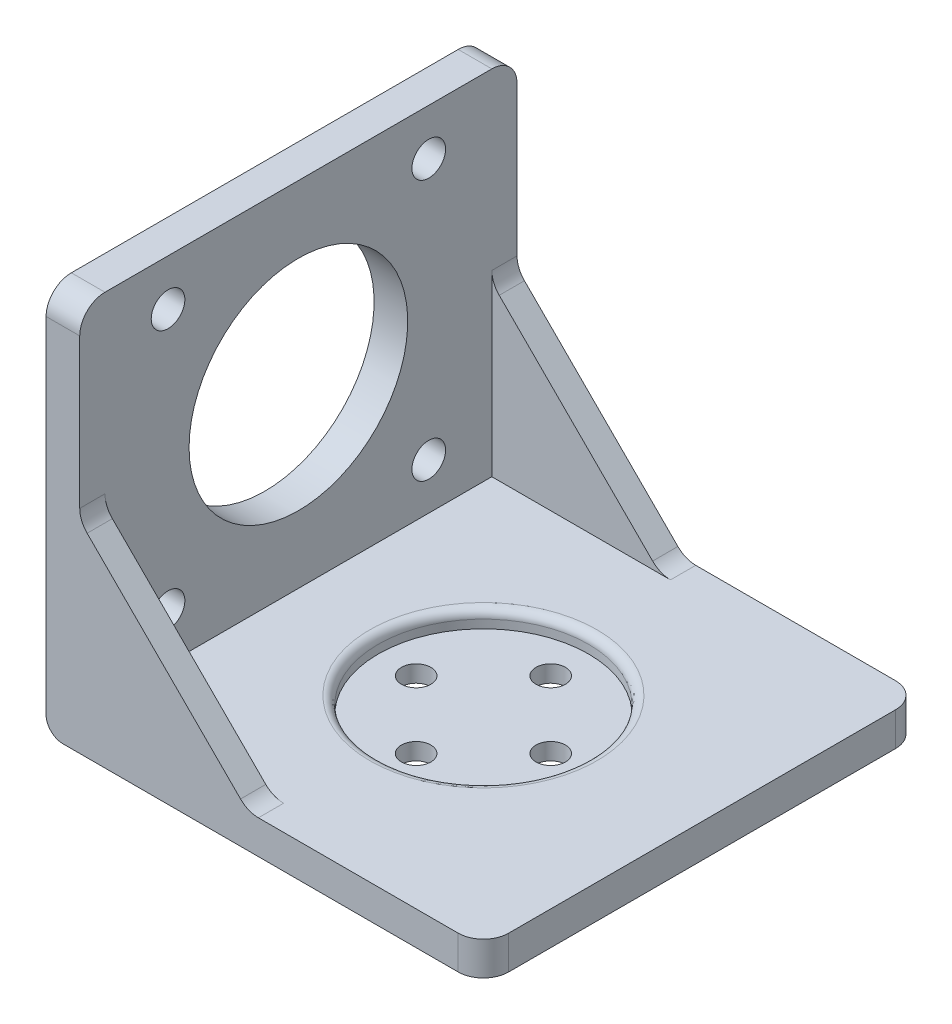
from build123d import *

# Parameters (mm, degrees)
SKETCH_1_W          = 52
SKETCH_1_H          = 46
SKETCH_1_R          = 1.75
EXTRUDE_2_DEPTH     = 4
SKETCH_2_W          = 46
SKETCH_2_H          = 42
SKETCH_2_R          = 2
SKETCH_2_R_2        = 13
EXTRUDE_3_DEPTH     = 4
SKETCH_4_R          = 12.5
CUT_EXTRUDE_1_DEPTH = 2
EXTRUDE_4_DEPTH     = 3
EXTRUDE_5_DEPTH     = 3
FILLET_1_R          = 3
FILLET_2_R          = 3
FILLET_3_R          = 3
FILLET_4_R          = 3
FILLET_5_R          = 3
FILLET_6_R          = 3
FILLET_7_R          = 3
FILLET_8_R          = 3
FILLET_9_R          = 1
FILLET_10_R         = 2


with BuildPart() as part:
    # 草图1 → 凸台-拉伸2 (new body)
    with BuildSketch(Plane(origin=(0, 0, 0), x_dir=(1, 0, 0), z_dir=(0, 1, 0))):
        Rectangle(SKETCH_1_W, SKETCH_1_H)
        with Locations((8, 0)):
            Circle(SKETCH_1_R, mode=Mode.SUBTRACT)
        with Locations((0, 8)):
            Circle(SKETCH_1_R, mode=Mode.SUBTRACT)
        with Locations((-8, 0)):
            Circle(SKETCH_1_R, mode=Mode.SUBTRACT)
        with Locations((0, -8)):
            Circle(SKETCH_1_R, mode=Mode.SUBTRACT)
    extrude(amount=EXTRUDE_2_DEPTH)

    # 草图2 → 凸台-拉伸3 (add)
    with BuildSketch(Plane.ZY.offset(26)):
        with Locations((0, 25)):
            Rectangle(SKETCH_2_W, SKETCH_2_H)
        with Locations((15.5, 40.5)):
            Circle(SKETCH_2_R, mode=Mode.SUBTRACT)
        with Locations((15.5, 9.5)):
            Circle(SKETCH_2_R, mode=Mode.SUBTRACT)
        with Locations((-15.5, 9.5)):
            Circle(SKETCH_2_R, mode=Mode.SUBTRACT)
        with Locations((-15.5, 40.5)):
            Circle(SKETCH_2_R, mode=Mode.SUBTRACT)
        with Locations((0, 25)):
            Circle(SKETCH_2_R_2, mode=Mode.SUBTRACT)
    extrude(amount=-EXTRUDE_3_DEPTH)

    # 草图4 → 切除-拉伸1 (cut)
    with BuildSketch(Plane(origin=(0, 4, 0), x_dir=(1, 0, 0), z_dir=(0, 1, 0))):
        Circle(SKETCH_4_R)
    extrude(amount=-CUT_EXTRUDE_1_DEPTH, mode=Mode.SUBTRACT)

    # 草图6 → 凸台-拉伸4 (add)
    with BuildSketch(Plane.XY.offset(23)):
        Polygon((-26, 46), (-22, 46), (-22, 24), (-2, 4), (26, 4), (26, 0), (-26, 0), align=None)
    extrude(amount=EXTRUDE_4_DEPTH)

    # 草图7 → 凸台-拉伸5 (add)
    with BuildSketch(Plane(origin=(0, 0, -23), x_dir=(-1, 0, 0), z_dir=(0, 0, -1))):
        Polygon((26, 46), (26, 0), (-26, 0), (-26, 4), (2, 4), (22, 24), (22, 46), align=None)
    extrude(amount=EXTRUDE_5_DEPTH)

    # 圆角1
    fillet_1_edges = [part.edges().sort_by_distance(p)[0] for p in [
        (-24, 46, 26),
    ]]
    fillet(fillet_1_edges, radius=FILLET_1_R)

    # 圆角2
    fillet_2_edges = [part.edges().sort_by_distance(p)[0] for p in [
        (-24, 46, -26),
    ]]
    fillet(fillet_2_edges, radius=FILLET_2_R)

    # 圆角3
    fillet_3_edges = [part.edges().sort_by_distance(p)[0] for p in [
        (26, 2, 26),
    ]]
    fillet(fillet_3_edges, radius=FILLET_3_R)

    # 圆角4
    fillet_4_edges = [part.edges().sort_by_distance(p)[0] for p in [
        (26, 2, -26),
    ]]
    fillet(fillet_4_edges, radius=FILLET_4_R)

    # 圆角5
    fillet_5_edges = [part.edges().sort_by_distance(p)[0] for p in [
        (-22, 24, 24.5),
    ]]
    fillet(fillet_5_edges, radius=FILLET_5_R)

    # 圆角6
    fillet_6_edges = [part.edges().sort_by_distance(p)[0] for p in [
        (-2, 4, 24.5),
    ]]
    fillet(fillet_6_edges, radius=FILLET_6_R)

    # 圆角7
    fillet_7_edges = [part.edges().sort_by_distance(p)[0] for p in [
        (-22, 24, -24.5),
    ]]
    fillet(fillet_7_edges, radius=FILLET_7_R)

    # 圆角8
    fillet_8_edges = [part.edges().sort_by_distance(p)[0] for p in [
        (-2, 4, -24.5),
    ]]
    fillet(fillet_8_edges, radius=FILLET_8_R)

    # 圆角9
    fillet_9_edges = [part.edges().sort_by_distance(p)[0] for p in [
        (-12.5, 4, 0),
    ]]
    fillet(fillet_9_edges, radius=FILLET_9_R)

    # 圆角10
    fillet_10_edges = [part.edges().sort_by_distance(p)[0] for p in [
        (-26, 0, 0),
    ]]
    fillet(fillet_10_edges, radius=FILLET_10_R)


solid = part.part
